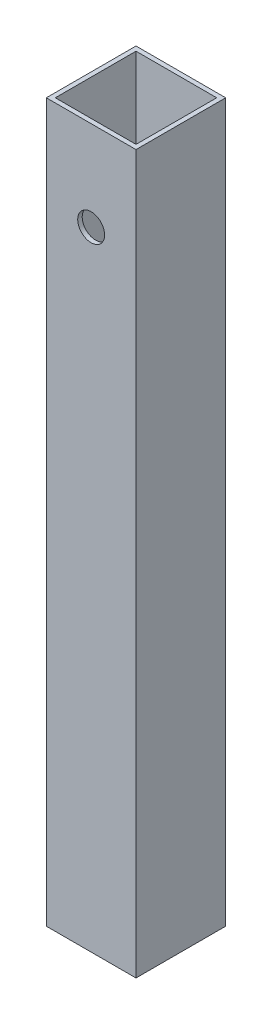
from build123d import *

# Parameters (mm, degrees)
SKETCH_1_W          = 20
SKETCH_1_H          = 20
SKETCH_1_W_2        = 18
SKETCH_1_H_2        = 18
EXTRUDE_1_DEPTH     = 140
SKETCH_2_W          = 20
SKETCH_2_H          = 20
EXTRUDE_2_DEPTH     = 20
SKETCH_3_R          = 3
CUT_EXTRUDE_1_DEPTH = 2


with BuildPart() as part:
    # 草图1 → 凸台-拉伸1 (new body)
    with BuildSketch(Plane(origin=(0, 0, 0), x_dir=(1, 0, 0), z_dir=(0, 1, 0))):
        Rectangle(SKETCH_1_W, SKETCH_1_H)
        Rectangle(SKETCH_1_W_2, SKETCH_1_H_2, mode=Mode.SUBTRACT)
    extrude(amount=EXTRUDE_1_DEPTH)

    # 草图2 → 凸台-拉伸2 (add)
    with BuildSketch(Plane.XZ):
        Rectangle(SKETCH_2_W, SKETCH_2_H)
    extrude(amount=EXTRUDE_2_DEPTH)

    # 草图3 → 切除-拉伸1 (cut)
    with BuildSketch(Plane.XY.offset(10)):
        with Locations((0, 120)):
            Circle(SKETCH_3_R)
    extrude(amount=-CUT_EXTRUDE_1_DEPTH, mode=Mode.SUBTRACT)


solid = part.part
